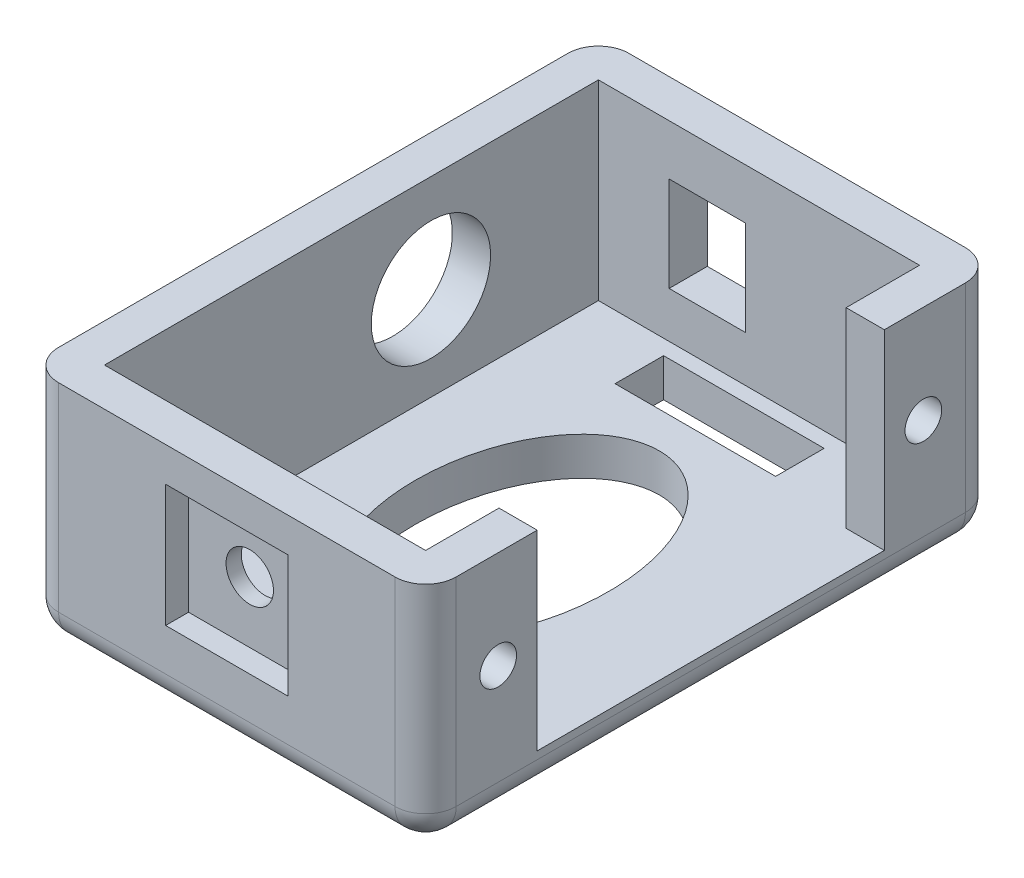
from build123d import *

# Parameters (mm, degrees)
BOSS_EXTRUDE1_DEPTH = 15
SKETCH2_W           = 32.3
SKETCH2_H           = 2.5
BOSS_EXTRUDE2_DEPTH = 23.5
SKETCH3_W           = 5
SKETCH3_H           = 6.2
CUT_EXTRUDE1_DEPTH  = 12.5
CUT_EXTRUDE2_REACH  = 28
SKETCH4_R           = 3.9
SKETCH5_R           = 1.2
CUT_EXTRUDE3_DEPTH  = 2.5
CUT_EXTRUDE4_REACH  = 39.3
SKETCH6_R           = 1.55
FILLET2_R           = 2
SKETCH7_W           = 8
SKETCH7_H           = 8
SKETCH7_R           = 1.55
CUT_EXTRUDE5_DEPTH  = 1.5
CUT_EXTRUDE6_REACH  = 4.5
SKETCH8_RX          = 9.634046057
SKETCH8_RY          = 6.312870092
SKETCH8_W           = 10.5
SKETCH8_H           = 3.175


with BuildPart() as part:
    # Sketch1 → Boss-Extrude1 (new body)
    with BuildSketch(Plane(origin=(0, 0, 0), x_dir=(1, 0, 0), z_dir=(0, 1, 0))):
        Polygon((0, 29.994099724), (-26, 29.994099724), (-26, -7.305900276), (0, -7.305900276), (0, -0.005900276), (-2.5, -0.005900276), (-2.5, -4.805900276), (-23.5, -4.805900276), (-23.5, 27.494099724), (-2.5, 27.494099724), (-2.5, 22.694099724), (0, 22.694099724), align=None)
    extrude(amount=BOSS_EXTRUDE1_DEPTH)

    # Sketch2 → Boss-Extrude2 (add, through all)
    with BuildSketch(Plane(origin=(-23.5, 0, 0), x_dir=(0, 0, -1), z_dir=(1, 0, 0))):
        with Locations((11.344099724, 1.25)):
            Rectangle(SKETCH2_W, SKETCH2_H)
    extrude(amount=BOSS_EXTRUDE2_DEPTH)

    # Sketch3 → Cut-Extrude1 (cut)
    with BuildSketch(Plane(origin=(0, 0, -29.994099724), x_dir=(-1, 0, 0), z_dir=(0, 0, -1))):
        with Locations((16.375, 8.6)):
            Rectangle(SKETCH3_W, SKETCH3_H)
    extrude(amount=-CUT_EXTRUDE1_DEPTH, mode=Mode.SUBTRACT)

    # Sketch4 → Cut-Extrude2 (cut, up to next)
    with BuildSketch(Plane.ZY.offset(26), mode=Mode.PRIVATE) as cut_extrude2_sk1:
        with Locations((-16.544099724, 8.6)):
            Circle(SKETCH4_R)
    cut_extrude2_tool1 = extrude(cut_extrude2_sk1.sketch, amount=-CUT_EXTRUDE2_REACH, mode=Mode.PRIVATE) & part.part
    add(cut_extrude2_tool1.solids().sort_by_distance((-26, 8.6, -16.5441))[0], mode=Mode.SUBTRACT)

    # Sketch5 → Cut-Extrude3 (cut)
    with BuildSketch(Plane(origin=(0, 0, 0), x_dir=(0, 0, -1), z_dir=(1, 0, 0))):
        with Locations((-2.555900276, 8.6)):
            Circle(SKETCH5_R)
    cut_extrude3 = extrude(amount=-CUT_EXTRUDE3_DEPTH, mode=Mode.SUBTRACT)

    # Mirror1: Cut-Extrude3 across plane
    add(cut_extrude3.mirror(Plane.XY.offset(-11.344099724)), mode=Mode.SUBTRACT)

    # Sketch6 → Cut-Extrude4 (cut, up to next)
    with BuildSketch(Plane.XY.offset(7.305900276), mode=Mode.PRIVATE) as cut_extrude4_sk1:
        with Locations((-13, 8.75)):
            Circle(SKETCH6_R)
    cut_extrude4_tool1 = extrude(cut_extrude4_sk1.sketch, amount=-CUT_EXTRUDE4_REACH, mode=Mode.PRIVATE) & part.part
    add(cut_extrude4_tool1.solids().sort_by_distance((-13, 8.75, 7.3059))[0], mode=Mode.SUBTRACT)

    # Fillet2
    fillet2_edges = [part.edges().sort_by_distance(p)[0] for p in [
        (0, 0, -11.344099724),
        (-13, 0, 7.305900276),
        (-26, 0, -11.344099724),
        (-13, 0, -29.994099724),
        (0, 7.5, 7.305900276),
        (-26, 7.5, 7.305900276),
        (-26, 7.5, -29.994099724),
        (0, 7.5, -29.994099724),
    ]]
    fillet(fillet2_edges, radius=FILLET2_R)

    # Sketch7 → Cut-Extrude5 (cut)
    with BuildSketch(Plane.XY.offset(7.305900276)):
        with Locations((-13, 8.75)):
            Rectangle(SKETCH7_W, SKETCH7_H)
        with Locations((-13, 8.75)):
            Circle(SKETCH7_R, mode=Mode.SUBTRACT)
    extrude(amount=-CUT_EXTRUDE5_DEPTH, mode=Mode.SUBTRACT)

    # Sketch8 → Cut-Extrude6 (cut, up to next)
    with BuildSketch(Plane(origin=(0, 2.5, 0), x_dir=(1, 0, 0), z_dir=(0, 1, 0)), mode=Mode.PRIVATE) as cut_extrude6_sk1:
        with Locations(Location((-13, 11.344099724), (0, 0, 90))):
            Ellipse(SKETCH8_RX, SKETCH8_RY)
    cut_extrude6_tool1 = extrude(cut_extrude6_sk1.sketch, amount=-CUT_EXTRUDE6_REACH, mode=Mode.PRIVATE) & part.part
    add(cut_extrude6_tool1.solids().sort_by_distance((-13, 2.5, -11.3441))[0], mode=Mode.SUBTRACT)
    # Sketch8 → Cut-Extrude6 (cut, up to next)
    with BuildSketch(Plane(origin=(0, 2.5, 0), x_dir=(1, 0, 0), z_dir=(0, 1, 0)), mode=Mode.PRIVATE) as cut_extrude6_sk2:
        with Locations((-13, -2.231384095)):
            Rectangle(SKETCH8_W, SKETCH8_H)
    cut_extrude6_tool2 = extrude(cut_extrude6_sk2.sketch, amount=-CUT_EXTRUDE6_REACH, mode=Mode.PRIVATE) & part.part
    add(cut_extrude6_tool2.solids().sort_by_distance((-13, 2.5, 2.231384))[0], mode=Mode.SUBTRACT)
    # Sketch8 → Cut-Extrude6 (cut, up to next)
    with BuildSketch(Plane(origin=(0, 2.5, 0), x_dir=(1, 0, 0), z_dir=(0, 1, 0)), mode=Mode.PRIVATE) as cut_extrude6_sk3:
        with Locations((-13, 24.919583542)):
            Rectangle(SKETCH8_W, SKETCH8_H)
    cut_extrude6_tool3 = extrude(cut_extrude6_sk3.sketch, amount=-CUT_EXTRUDE6_REACH, mode=Mode.PRIVATE) & part.part
    add(cut_extrude6_tool3.solids().sort_by_distance((-13, 2.5, -24.919584))[0], mode=Mode.SUBTRACT)


solid = part.part
